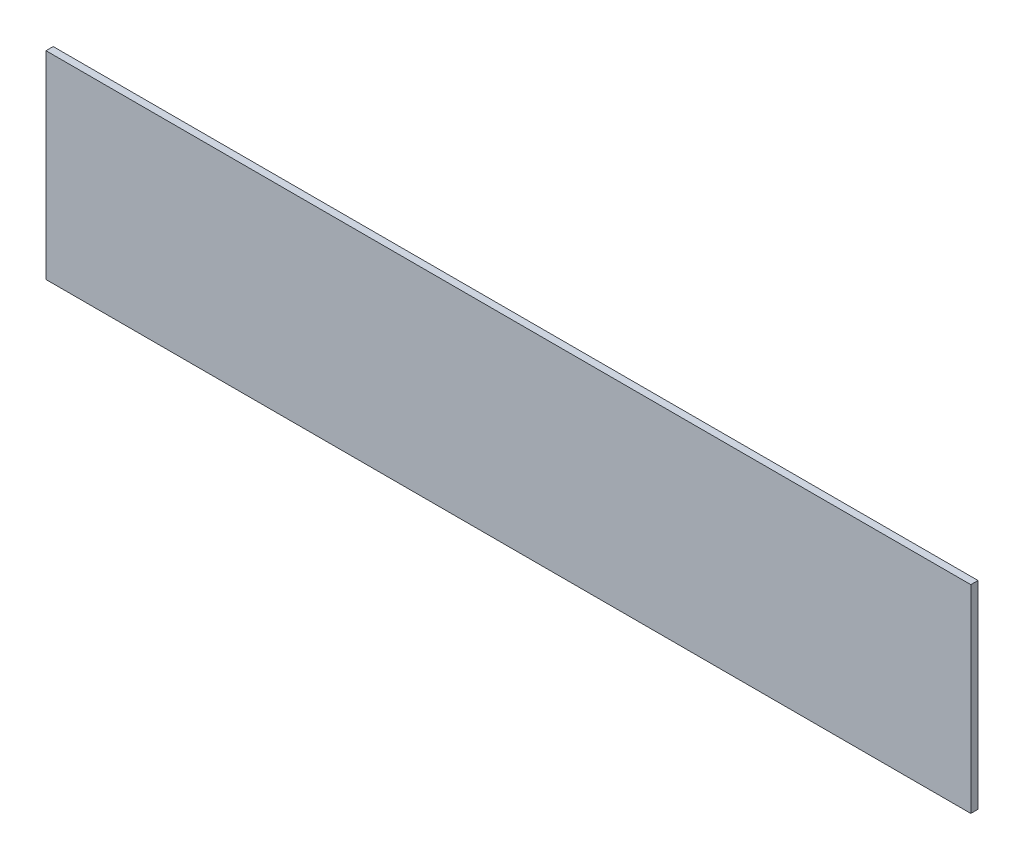
from build123d import *

# Parameters (mm, degrees)
CROQUIS1_W              = 385
CROQUIS1_H              = 82.5
SALIENTE_EXTRUIR1_DEPTH = 3


with BuildPart() as part:
    # Croquis1 → Saliente-Extruir1 (new body)
    with BuildSketch(Plane.XY):
        with Locations((192.5, 41.25)):
            Rectangle(CROQUIS1_W, CROQUIS1_H)
    extrude(amount=SALIENTE_EXTRUIR1_DEPTH)


solid = part.part
